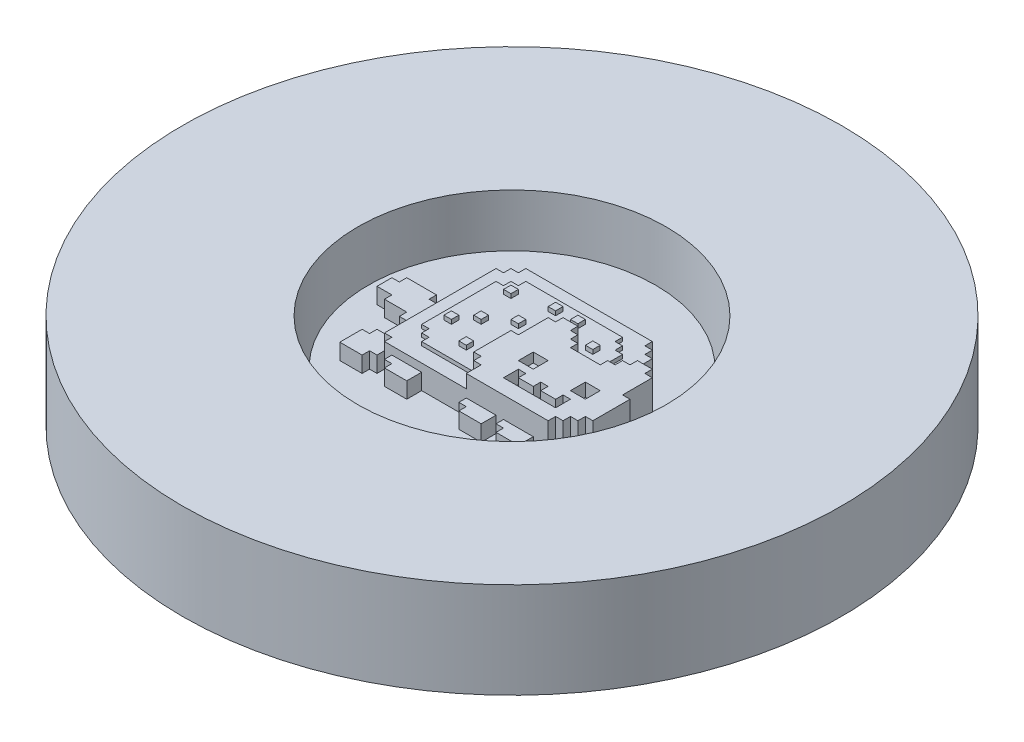
from build123d import *

# Parameters (mm, degrees)
FACE_3_W           = 7.112
FACE_3_H           = 7.112
FACE_2_DEPTH       = 17.78
FEETTAIL_DEPTH     = 7.62
POPTART_DEPTH      = 11.43
SPRINKLES_W        = 3.556
SPRINKLES_H        = 3.556
SPRINKLE_DEPTH     = 15.24
ENGRAVE_DEPTH      = 13.208
SKETCH2_R          = 68.58
CUPCAKE_DEPTH      = 15.24
RETAINING_START    = 21.59
SKETCH4_R          = 157.48
SKETCH4_R_2        = 73.66
RETAINING_DEPTH    = 45.72
CUPCAKE_START      = -17.78
SKETCH5_R          = 81.28
CUPCAKE_BODY_DEPTH = 6.35


with BuildPart() as part:
    # face 3 → face 2 (new body)
    with BuildSketch(Plane(origin=(0, 0, 0), x_dir=(1, 0, 0), z_dir=(0, 1, 0))):
        Polygon((103.124, 88.9), (110.236, 88.9), (110.236, 85.344), (113.792, 85.344), (113.792, 81.788), (117.348, 81.788), (117.348, 78.232), (131.572, 78.232), (131.572, 81.788), (135.128, 81.788), (135.128, 85.344), (138.684, 85.344), (138.684, 88.9), (145.796, 88.9), (145.796, 85.344), (149.352, 85.344), (149.352, 71.12), (152.908, 71.12), (152.908, 53.34), (149.352, 53.34), (149.352, 49.784), (145.796, 49.784), (145.796, 46.228), (142.24, 46.228), (142.24, 42.672), (103.124, 42.672), (103.124, 49.784), (99.568, 49.784), (99.568, 53.34), (96.012, 53.34), (96.012, 71.12), (99.568, 71.12), (99.568, 85.344), (103.124, 85.344), align=None)
        with Locations((113.792, 64.008)):
            Rectangle(FACE_3_W, FACE_3_H, mode=Mode.SUBTRACT)
        with Locations((138.684, 64.008)):
            Rectangle(FACE_3_W, FACE_3_H, mode=Mode.SUBTRACT)
        Polygon((113.792, 56.896), (113.792, 49.784), (138.684, 49.784), (138.684, 56.896), (135.128, 56.896), (135.128, 53.34), (128.016, 53.34), (128.016, 56.896), (124.46, 56.896), (124.46, 53.34), (117.348, 53.34), (117.348, 56.896), align=None, mode=Mode.SUBTRACT)
    extrude(amount=FACE_2_DEPTH)

    # feet tail → feettail (add)
    with BuildSketch(Plane(origin=(0, 0, 0), x_dir=(1, 0, 0), z_dir=(0, 1, 0))):
        Polygon((60.452, 74.676), (53.34, 74.676), (53.34, 78.232), (39.116, 78.232), (39.116, 74.676), (35.56, 74.676), (35.56, 67.564), (42.672, 67.564), (42.672, 64.008), (53.34, 64.008), (53.34, 60.452), (60.452, 60.452), align=None)
        Polygon((60.452, 53.34), (56.896, 53.34), (56.896, 49.784), (53.34, 49.784), (53.34, 46.228), (49.784, 46.228), (49.784, 35.56), (60.452, 35.56), (60.452, 39.116), (64.008, 39.116), (64.008, 46.228), (60.452, 46.228), align=None)
        Polygon((67.564, 42.672), (67.564, 39.116), (71.12, 39.116), (71.12, 35.56), (81.788, 35.56), (81.788, 42.672), align=None)
        Polygon((103.124, 42.672), (103.124, 39.116), (106.68, 39.116), (106.68, 35.56), (117.348, 35.56), (117.348, 42.672), align=None)
        Polygon((120.904, 42.672), (120.904, 39.116), (124.46, 39.116), (124.46, 35.56), (135.128, 35.56), (135.128, 42.672), align=None)
    extrude(amount=FEETTAIL_DEPTH)


with BuildPart() as feettail_piece_1:
    # of the separate pieces the step leaves, piece 1, a body of its own (feettail_pieces)
    add(part.part.solids().sort_by_distance((103.124, 0, -88.9))[0])



with BuildPart() as feettail_piece_2:
    # of the separate pieces the step leaves, piece 2, a body of its own (feettail_pieces)
    add(part.part.solids().sort_by_distance((60.452, 0, -74.676))[0])


with BuildPart() as feettail_piece_3:
    # of the separate pieces the step leaves, piece 3, a body of its own (feettail_pieces)
    add(part.part.solids().sort_by_distance((60.452, 0, -53.34))[0])


with BuildPart() as feettail_piece_4:
    # of the separate pieces the step leaves, piece 4, a body of its own (feettail_pieces)
    add(part.part.solids().sort_by_distance((67.564, 0, -42.672))[0])


with BuildPart() as feettail_piece_1_1:
    add(feettail_piece_1.part)

    add(feettail_piece_3.part)  # poptart merges feettail piece 3

    add(feettail_piece_4.part)  # poptart merges feettail piece 4
    # poptart 2 → poptart (add)
    with BuildSketch(Plane(origin=(0, 0, 0), x_dir=(1, 0, 0), z_dir=(0, 1, 0))):
        Polygon((135.128, 99.568), (131.572, 99.568), (131.572, 103.124), (128.016, 103.124), (128.016, 106.68), (67.564, 106.68), (67.564, 103.124), (64.008, 103.124), (64.008, 99.568), (60.452, 99.568), (60.452, 46.228), (64.008, 46.228), (64.008, 42.672), (135.128, 42.672), (145.796, 53.34), (145.796, 71.12), (135.128, 85.344), align=None)
    extrude(amount=POPTART_DEPTH)

    # sprinkles → sprinkle (add)
    with BuildSketch(Plane(origin=(0, 0, 0), x_dir=(1, 0, 0), z_dir=(0, 1, 0))):
        with Locations((72.898, 65.786)):
            Rectangle(SPRINKLES_W, SPRINKLES_H)
        with Locations((80.01, 72.898)):
            Rectangle(SPRINKLES_W, SPRINKLES_H)
        with Locations((90.678, 80.01)):
            Rectangle(SPRINKLES_W, SPRINKLES_H)
        with Locations((76.454, 90.678)):
            Rectangle(SPRINKLES_W, SPRINKLES_H)
        with Locations((94.234, 94.234)):
            Rectangle(SPRINKLES_W, SPRINKLES_H)
        with Locations((104.902, 94.234)):
            Rectangle(SPRINKLES_W, SPRINKLES_H)
        with Locations((119.126, 87.122)):
            Rectangle(SPRINKLES_W, SPRINKLES_H)
        with Locations((87.122, 58.674)):
            Rectangle(SPRINKLES_W, SPRINKLES_H)
    extrude(amount=SPRINKLE_DEPTH)

    # engrave poptart → engrave (add)
    with BuildSketch(Plane(origin=(0, 0, 0), x_dir=(1, 0, 0), z_dir=(0, 1, 0))):
        Polygon((71.12, 53.34), (74.676, 53.34), (74.676, 49.784), (99.816268886, 49.760009936), (99.568, 49.784), (128.016, 64.008), (128.016, 67.564), (128.016, 92.456), (124.46, 92.456), (124.46, 96.012), (120.904, 96.012), (120.904, 99.568), (74.676, 99.568), (74.676, 96.012), (71.12, 96.012), (71.12, 92.456), (67.564, 92.456), (67.564, 56.896), (71.12, 56.896), align=None)
    extrude(amount=ENGRAVE_DEPTH)


    add(feettail_piece_2.part)  # CUPCAKE merges feettail piece 2
    # Sketch2 → CUPCAKE (add)
    with BuildSketch(Plane(origin=(0, 0, 0), x_dir=(1, 0, 0), z_dir=(0, 1, 0))):
        with Locations(Location((93.98, 73.66, 0), (0, 0, 270))):
            Circle(SKETCH2_R)
    extrude(amount=-CUPCAKE_DEPTH)


with BuildPart() as body_2:
    # Sketch4 → retaining (new body)
    with BuildSketch(Plane(origin=(0, 0, 0), x_dir=(1, 0, 0), z_dir=(0, 1, 0)).offset(RETAINING_START)):
        with Locations(Location((93.98, 73.66, 0), (0, 0, 270))):
            Circle(SKETCH4_R)
        with Locations(Location((93.98, 73.66, 0), (0, 0, 270))):
            Circle(SKETCH4_R_2, mode=Mode.SUBTRACT)
    extrude(amount=-RETAINING_DEPTH)


with BuildPart() as body_3:
    # Sketch5 → cupcake body (new body)
    with BuildSketch(Plane(origin=(0, 0, 0), x_dir=(1, 0, 0), z_dir=(0, 1, 0)).offset(CUPCAKE_START)):
        with Locations(Location((93.98, 73.66, 0), (0, 0, 270))):
            Circle(SKETCH5_R)
    extrude(amount=-CUPCAKE_BODY_DEPTH)


solid = Compound([feettail_piece_1_1.part, body_2.part, body_3.part])
